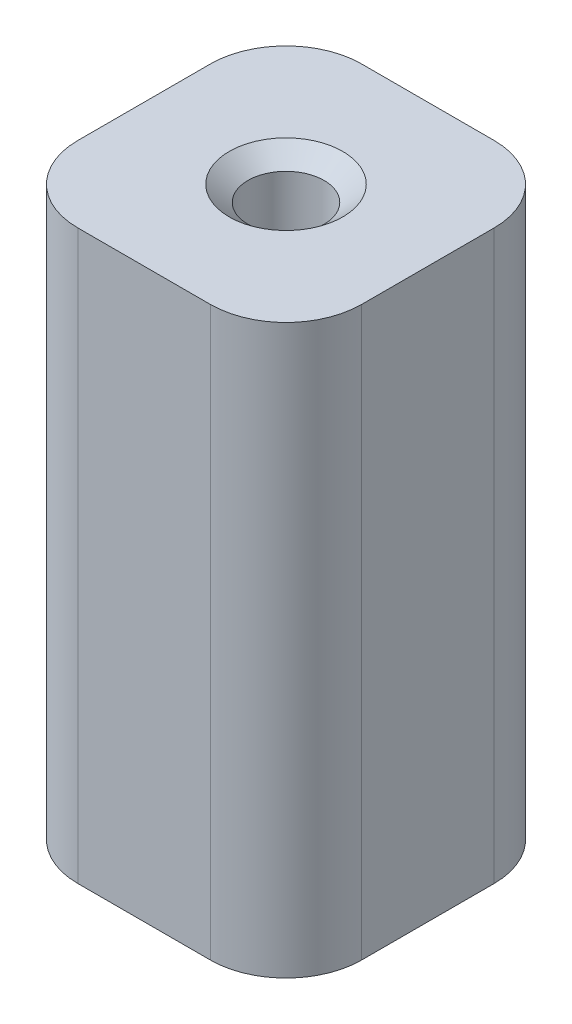
from build123d import *

# Parameters (mm, degrees)
SKETCH1_W                         = 19.05
SKETCH1_H                         = 19.05
BOSS_EXTRUDE1_DEPTH               = 38.1
F_1_4_20_TAPPED_HOLE1_D           = 5.1054
F_1_4_20_TAPPED_HOLE1_DEPTH       = 25.4
F_1_4_20_TAPPED_HOLE1_CSINK_D     = 7.62
F_1_4_20_TAPPED_HOLE1_CSINK_ANGLE = 100
F_1_4_20_TAPPED_HOLE1_TIP         = 1.533816902
FILLET1_R                         = 5.08


with BuildPart() as part:
    # Sketch1 → Boss-Extrude1 (new body)
    with BuildSketch(Plane(origin=(0, 0, 0), x_dir=(1, 0, 0), z_dir=(0, 1, 0))):
        Rectangle(SKETCH1_W, SKETCH1_H)
    extrude(amount=BOSS_EXTRUDE1_DEPTH)

    # 1/4-20 Tapped Hole1
    with Locations(Plane(origin=(0, 38.1, 0), x_dir=(1, 0, 0), z_dir=(0, 1, 0))):
        with Locations((0, 0)):
            CounterSinkHole(F_1_4_20_TAPPED_HOLE1_D / 2, F_1_4_20_TAPPED_HOLE1_CSINK_D / 2, depth=F_1_4_20_TAPPED_HOLE1_DEPTH, counter_sink_angle=F_1_4_20_TAPPED_HOLE1_CSINK_ANGLE)
            with Locations((0, 0, -(F_1_4_20_TAPPED_HOLE1_DEPTH + F_1_4_20_TAPPED_HOLE1_TIP / 2))):  # 118° drill point
                Cone(0, F_1_4_20_TAPPED_HOLE1_D / 2, F_1_4_20_TAPPED_HOLE1_TIP, mode=Mode.SUBTRACT)

    # Fillet1
    fillet1_edges = [part.edges().sort_by_distance(p)[0] for p in [
        (9.525, 19.05, 9.525),
        (-9.525, 19.05, 9.525),
        (-9.525, 19.05, -9.525),
        (9.525, 19.05, -9.525),
    ]]
    fillet(fillet1_edges, radius=FILLET1_R)


solid = part.part
